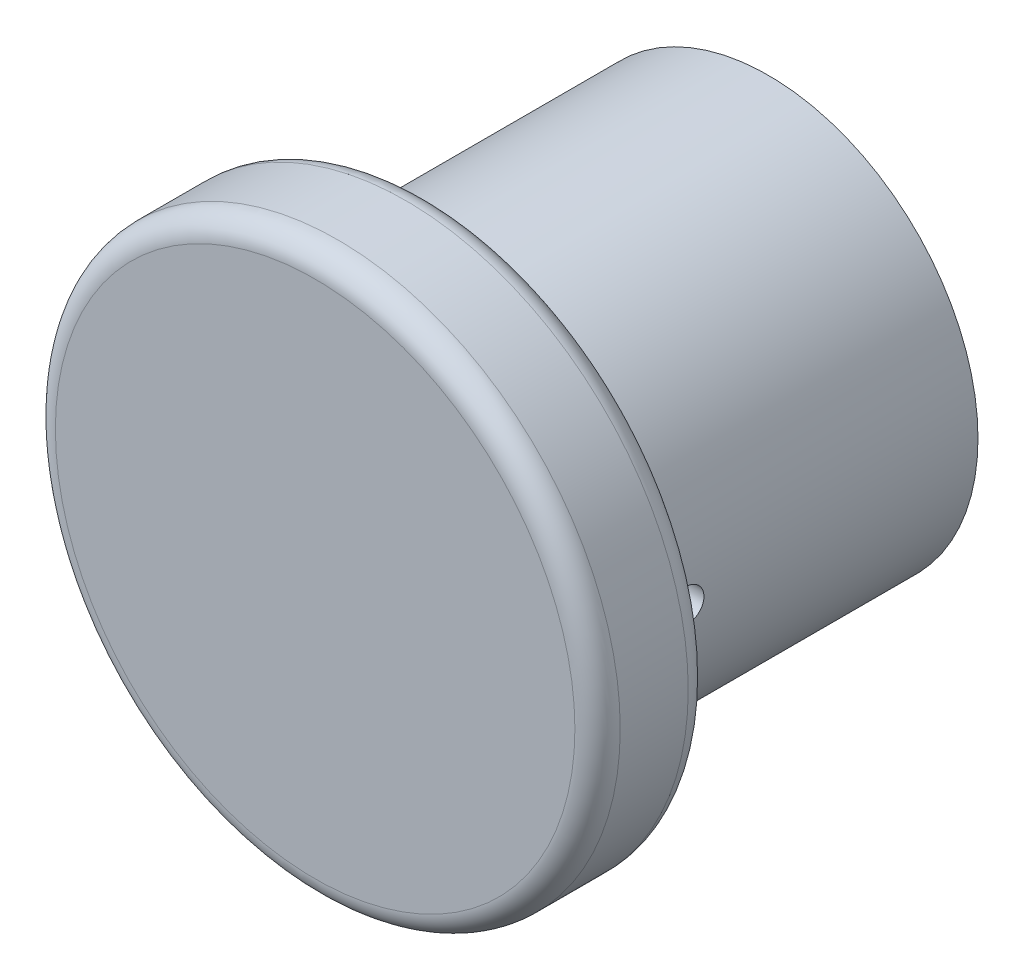
from build123d import *

# Parameters (mm, degrees)
SKETCH1_R           = 12.461427854
BASE_EXTRUDE_DEPTH  = 5
SKETCH2_R           = 9.246210184
BOSS_EXTRUDE1_DEPTH = 15
SKETCH3_W           = 6.4135
SKETCH3_H           = 13.726679844
SKETCH4_W           = 2.875338505
SKETCH4_H           = 0.738225097
SKETCH5_W           = 2.875338506
SKETCH5_H           = 0.738225097
FILLET1_R           = 1


with BuildPart() as part:
    # Sketch1 → Base-Extrude (new body)
    with BuildSketch(Plane(origin=(0, 0, 0), x_dir=(-1, 0, 0), z_dir=(0, 0, -1))):
        Circle(SKETCH1_R)
    extrude(amount=-BASE_EXTRUDE_DEPTH)

    # Sketch2 → Boss-Extrude1 (add)
    with BuildSketch(Plane(origin=(0, 0, 0), x_dir=(-1, 0, 0), z_dir=(0, 0, -1))):
        Circle(SKETCH2_R)
    extrude(amount=BOSS_EXTRUDE1_DEPTH)

    # Sketch3 → Cut-Revolve1 (revolve, cut)
    with BuildSketch(Plane.XZ):
        with Locations((3.20675, -8.136660078)):
            Rectangle(SKETCH3_W, SKETCH3_H)
    revolve(axis=Axis((0, 0, -1.273320156), (0, 0, -1)), mode=Mode.SUBTRACT)

    # Sketch4 → Cut-Revolve2 (revolve, cut)
    with BuildSketch(Plane(origin=(0, 0, 0), x_dir=(1, 0, 0), z_dir=(0, 1, 0))):
        with Locations((-7.808540932, 2.539892603)):
            Rectangle(SKETCH4_W, SKETCH4_H)
    revolve(axis=Axis((-9.246210184, 0, -2.170780054), (1, 0, 0)), mode=Mode.SUBTRACT)

    # Sketch5 → Cut-Revolve3 (revolve, cut)
    with BuildSketch(Plane(origin=(0, 0, 0), x_dir=(1, 0, 0), z_dir=(0, 1, 0))):
        with Locations((7.808540932, 2.539892603)):
            Rectangle(SKETCH5_W, SKETCH5_H)
    revolve(axis=Axis((6.370871679, 0, -2.170780054), (1, 0, 0)), mode=Mode.SUBTRACT)

    # Fillet1
    fillet1_edges = [part.edges().sort_by_distance(p)[0] for p in [
        (12.461427854, 0, 0),
        (12.461427854, 0, 5),
        (9.246210184, 0, 0),
    ]]
    fillet(fillet1_edges, radius=FILLET1_R)


solid = part.part
